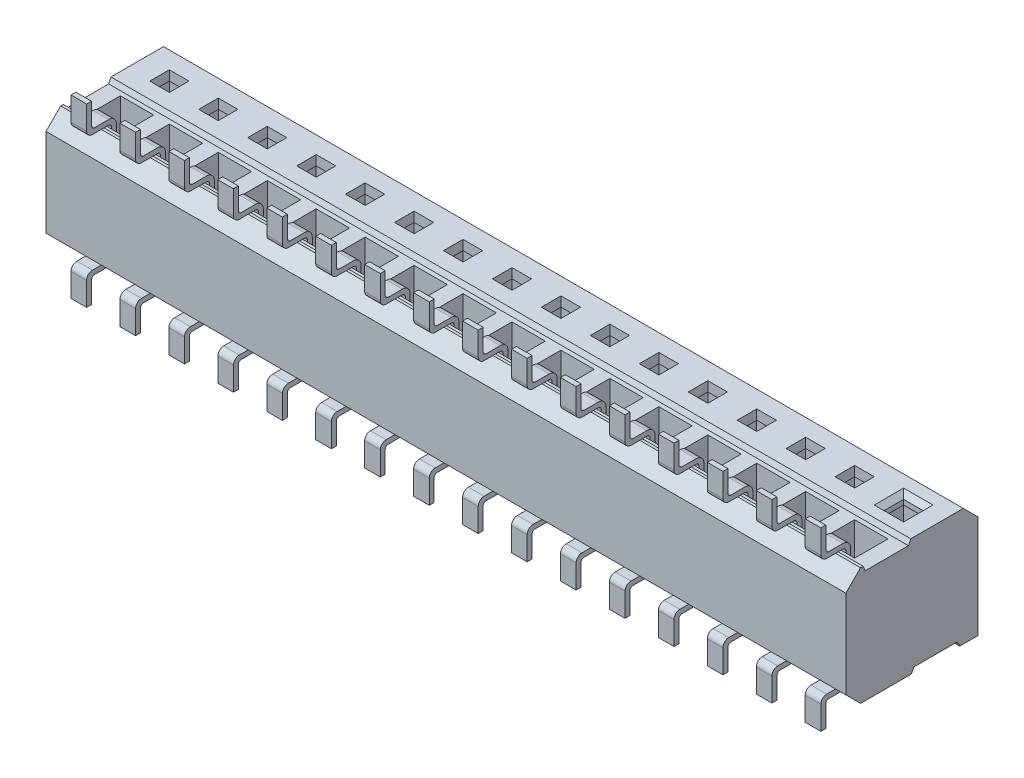
from build123d import *

# Parameters (mm, degrees)
SKETCH1_W             = 20.7518
SKETCH1_H             = 3.429
MAIN_BODY_DEPTH       = 3.048
SKETCH2_W             = 0.508
SKETCH2_H             = 0.508
CUT_EXTRUDE1_DEPTH    = 2.794
CHAMFER1_SIZE         = 0.127
SKETCH30_W            = 0.8636
SKETCH30_H            = 2.794
PIN_CUT_DH_DEPTH      = 0.4318
BODY_CUT_DH_DEPTH     = 21.7518
DH_CUT_PATTERN_COUNT  = 16
DH_CUT_PATTERN_PITCH  = 1.27
LEAD_PIN_DH_DEPTH     = 0.2032
LEAD_PATTERN_DH_COUNT = 16
LEAD_PATTERN_DH_PITCH = 1.27


with BuildPart() as part:
    # Sketch1 → Main Body (new body)
    with BuildSketch(Plane(origin=(0, 0, 0), x_dir=(1, 0, 0), z_dir=(0, 1, 0))):
        Rectangle(SKETCH1_W, SKETCH1_H)
    extrude(amount=MAIN_BODY_DEPTH)

    # Sketch2 → Cut-Extrude1 (cut)
    with BuildSketch(Plane(origin=(0, 3.048, 0), x_dir=(-1, 0, 0), z_dir=(0, 1, 0))):
        with Locations((-9.525, -0.635)):
            Rectangle(SKETCH2_W, SKETCH2_H)
        with Locations((-9.525, 0.635)):
            Rectangle(SKETCH2_W, SKETCH2_H)
    cut_extrude1 = extrude(amount=-CUT_EXTRUDE1_DEPTH, mode=Mode.SUBTRACT)

    # Chamfer1
    chamfer1_edges = [part.edges().sort_by_distance(p)[0] for p in [
        (9.779, 3.048, -0.635),
        (9.525, 3.048, -0.889),
        (9.271, 3.048, -0.635),
        (9.525, 3.048, -0.381),
        (9.525, 3.048, 0.381),
        (9.271, 3.048, 0.635),
        (9.525, 3.048, 0.889),
        (9.779, 3.048, 0.635),
    ]]
    chamfer(chamfer1_edges, length=CHAMFER1_SIZE)

    # Sketch30 → Pin Cut-DH (cut, symmetric)
    with BuildSketch(Plane(origin=(9.525, 0, 0), x_dir=(0, 0, -1), z_dir=(1, 0, 0))):
        with Locations((-0.635, 1.651)):
            Rectangle(SKETCH30_W, SKETCH30_H)
        with Locations((0.635, 1.397)):
            Rectangle(SKETCH30_W, SKETCH30_H)
    pin_cut_dh = extrude(amount=PIN_CUT_DH_DEPTH, both=True, mode=Mode.SUBTRACT)

    # Sketch10 → Body Cut-DH (cut, through all)
    with BuildSketch(Plane(origin=(10.3759, 0, 0), x_dir=(0, 0, -1), z_dir=(1, 0, 0))):
        Polygon((-1.7145, 3.048), (-1.3335, 3.048), (-1.7145, 2.667), align=None)
        Polygon((-1.26492, 3.048), (-0.03048, 3.048), (-0.0889, 2.921), (-1.2065, 2.921), align=None)
        Polygon((1.7145, 2.667), (1.3335, 3.048), (1.7145, 3.048), align=None)
        Polygon((-1.7145, 0.381), (-1.3335, 0), (-1.7145, 0), align=None)
        Polygon((-0.01524, 0), (0.05334, 0.127), (1.17094, 0.127), (1.23952, 0), align=None)
    extrude(amount=-BODY_CUT_DH_DEPTH, mode=Mode.SUBTRACT)

    # DH Cut Pattern: Cut-Extrude1, Pin Cut-DH ×16
    with Locations(*[(-i * DH_CUT_PATTERN_PITCH, 0, 0) for i in range(1, DH_CUT_PATTERN_COUNT)]):
        add(cut_extrude1, mode=Mode.SUBTRACT)
        add(pin_cut_dh, mode=Mode.SUBTRACT)

    # Sketch11 → Lead Pin-DH (add, symmetric)
    with BuildSketch(Plane(origin=(9.525, 0, 0), x_dir=(0, 0, -1), z_dir=(1, 0, 0))):
        with BuildLine():
            Line((-1.5621, 3.048), (-1.143, 3.048))
            ThreePointArc((-1.143, 3.048), (-1.089118463, 3.025681537), (-1.0668, 2.9718))
            Line((-1.0668, 2.9718), (-1.0668, 2.48666))
            Line((-1.0668, 2.48666), (-0.9398, 2.48666))
            Line((-0.9398, 2.48666), (-0.9398, 2.9718))
            ThreePointArc((-0.9398, 2.9718), (-0.999315902, 3.115484098), (-1.143, 3.175))
            Line((-1.143, 3.175), (-1.5113, 3.175))
            ThreePointArc((-1.5113, 3.175), (-1.565181537, 3.197318463), (-1.5875, 3.2512))
            Line((-1.5875, 3.2512), (-1.5875, 3.81))
            Line((-1.5875, 3.81), (-1.7145, 3.81))
            Line((-1.7145, 3.81), (-1.7145, 3.2004))
            ThreePointArc((-1.7145, 3.2004), (-1.669863073, 3.092636927), (-1.5621, 3.048))
        make_face()
        with BuildLine():
            Line((0.2032, 0.686543888), (0.2032, 0.0762))
            ThreePointArc((0.2032, 0.0762), (0.180881537, 0.022318463), (0.127, 0))
            Line((0.127, 0), (-1.5621, 0))
            ThreePointArc((-1.5621, 0), (-1.669863073, -0.044636927), (-1.7145, -0.1524))
            Line((-1.7145, -0.1524), (-1.7145, -0.762))
            Line((-1.7145, -0.762), (-1.5875, -0.762))
            Line((-1.5875, -0.762), (-1.5875, -0.2032))
            ThreePointArc((-1.5875, -0.2032), (-1.565181537, -0.149318463), (-1.5113, -0.127))
            Line((-1.5113, -0.127), (0.127, -0.127))
            ThreePointArc((0.127, -0.127), (0.270684098, -0.067484098), (0.3302, 0.0762))
            Line((0.3302, 0.0762), (0.3302, 0.686543888))
            Line((0.3302, 0.686543888), (0.2032, 0.686543888))
        make_face()
    lead_pin_dh = extrude(amount=LEAD_PIN_DH_DEPTH, both=True)

    # Lead Pattern-DH: Lead Pin-DH ×16
    with Locations(*[(-i * LEAD_PATTERN_DH_PITCH, 0, 0) for i in range(1, LEAD_PATTERN_DH_COUNT)]):
        add(lead_pin_dh)


solid = part.part
